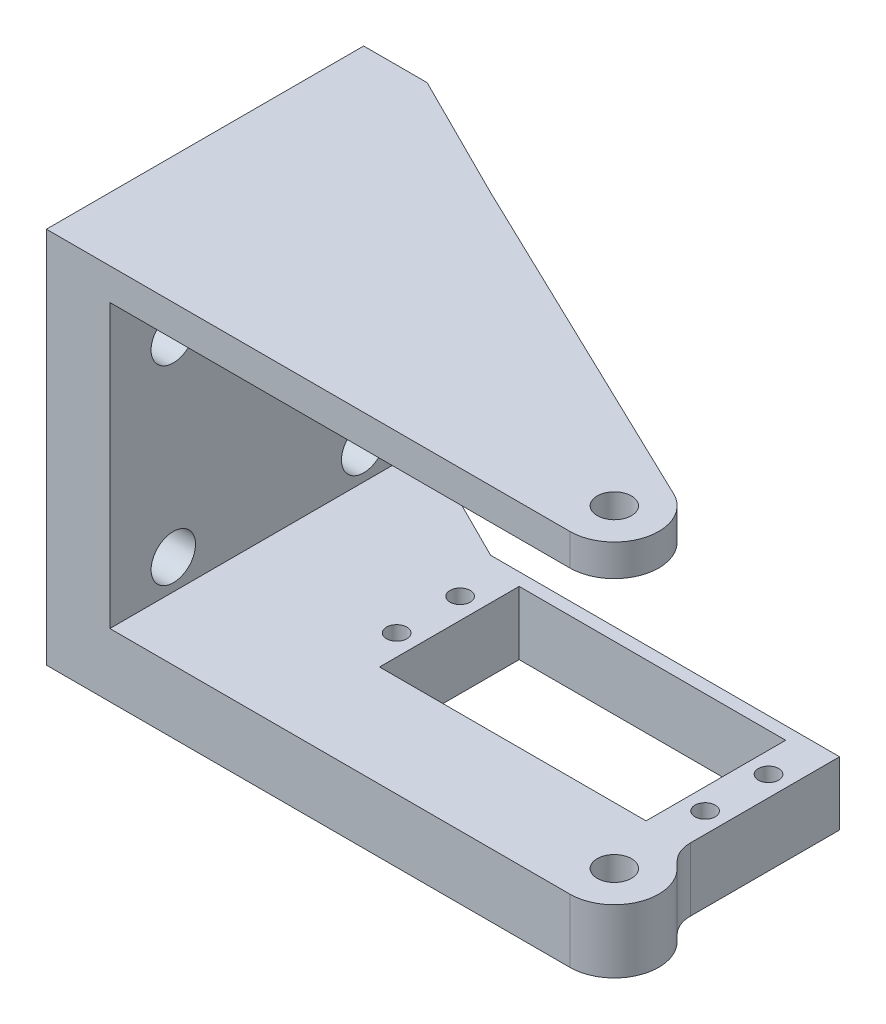
from build123d import *

# Parameters (mm, degrees)
SKETCH1_R           = 1.6
SKETCH1_R_2         = 5
SKETCH1_W           = 42
SKETCH1_H           = 22
BOSS_EXTRUDE1_DEPTH = 10
BOSS_EXTRUDE2_DEPTH = 10
BOSS_EXTRUDE4_START = 44.5
SKETCH2_R           = 5
BOSS_EXTRUDE4_DEPTH = 5
BOSS_EXTRUDE3_START = -10
SKETCH1_5_W         = 10
SKETCH1_5_H         = 50
BOSS_EXTRUDE3_DEPTH = 54.5
SKETCH3_R           = 3.5
CUT_EXTRUDE1_DEPTH  = 10
SKETCH4_R           = 5
SKETCH4_R_2         = 2.7
BOSS_EXTRUDE5_DEPTH = 10
BOSS_EXTRUDE6_START = 44.5
SKETCH4_2_R         = 5
SKETCH4_2_R_2       = 2.7
BOSS_EXTRUDE6_DEPTH = 5


with BuildPart() as part:
    # Sketch1 → Boss-Extrude1 (new body)
    with BuildSketch(Plane(origin=(0, 0, 0), x_dir=(1, 0, 0), z_dir=(0, 1, 0))):
        with BuildLine():
            Line((4.949747468, 4.949747468), (3.964466094, 5.935028843))
            ThreePointArc((3.964466094, 5.935028843), (2.880602337, 7.557145587), (2.5, 9.470562748))
            Line((2.5, 9.470562748), (2.5, 33))
            Line((2.5, 33), (-52.5, 33))
            Line((-52.5, 33), (-52.5, -7))
            Line((-52.5, -7), (0, -7))
            ThreePointArc((0, -7), (6.467156728, -2.678784027), (4.949747468, 4.949747468))
        make_face()
        with Locations((-49.3, 25)):
            Circle(SKETCH1_R, mode=Mode.SUBTRACT)
        with Locations((-49.3, 15)):
            Circle(SKETCH1_R, mode=Mode.SUBTRACT)
        with Locations((-0.7, 15)):
            Circle(SKETCH1_R, mode=Mode.SUBTRACT)
        with Locations((-0.7, 25)):
            Circle(SKETCH1_R, mode=Mode.SUBTRACT)
        Circle(SKETCH1_R_2, mode=Mode.SUBTRACT)
        with Locations((-25, 20)):
            Rectangle(SKETCH1_W, SKETCH1_H, mode=Mode.SUBTRACT)
    extrude(amount=-BOSS_EXTRUDE1_DEPTH)

    # Sketch1_4 → Boss-Extrude2 (add)
    with BuildSketch(Plane(origin=(0, 0, 0), x_dir=(1, 0, 0), z_dir=(0, 1, 0))):
        Polygon((-72.5, -7), (-52.5, -7), (-52.5, 33), (-72.5, 43), align=None)
    extrude(amount=-BOSS_EXTRUDE2_DEPTH)



with BuildPart() as body_2:
    # Sketch2 → Boss-Extrude4 (new body)
    with BuildSketch(Plane(origin=(0, 0, 0), x_dir=(1, 0, 0), z_dir=(0, 1, 0)).offset(BOSS_EXTRUDE4_START)):
        with BuildLine():
            Line((-72.5, 43), (-52.5, 33))
            Line((-52.5, 33), (3.032382393, 6.309093201))
            ThreePointArc((3.032382393, 6.309093201), (6.825088, -1.555047844), (0, -7))
            Line((0, -7), (-52.5, -7))
            Line((-52.5, -7), (-82.5, -7))
            Line((-82.5, -7), (-82.5, 43))
            Line((-82.5, 43), (-72.5, 43))
        make_face()
        Circle(SKETCH2_R, mode=Mode.SUBTRACT)
    extrude(amount=BOSS_EXTRUDE4_DEPTH)


with BuildPart() as part_1:
    add(part.part)

    add(body_2.part)  # Boss-Extrude3 merges body 2
    # Sketch1_5 → Boss-Extrude3 (add)
    with BuildSketch(Plane(origin=(0, 0, 0), x_dir=(1, 0, 0), z_dir=(0, 1, 0)).offset(BOSS_EXTRUDE3_START)):
        with Locations((-77.5, 18)):
            Rectangle(SKETCH1_5_W, SKETCH1_5_H)
    extrude(amount=BOSS_EXTRUDE3_DEPTH)

    # Sketch3 → Cut-Extrude1 (cut)
    with BuildSketch(Plane.ZY.offset(82.5)):
        with Locations((-3, 34.75)):
            Circle(SKETCH3_R)
        with Locations((-3, 4.75)):
            Circle(SKETCH3_R)
        with Locations((-33, 4.75)):
            Circle(SKETCH3_R)
        with Locations((-33, 34.75)):
            Circle(SKETCH3_R)
    extrude(amount=-CUT_EXTRUDE1_DEPTH, mode=Mode.SUBTRACT)

    # Sketch4 → Boss-Extrude5 (add)
    with BuildSketch(Plane(origin=(0, 0, 0), x_dir=(1, 0, 0), z_dir=(0, 1, 0))):
        Circle(SKETCH4_R)
        Circle(SKETCH4_R_2, mode=Mode.SUBTRACT)
    extrude(amount=-BOSS_EXTRUDE5_DEPTH)

    # Sketch4_2 → Boss-Extrude6 (add)
    with BuildSketch(Plane(origin=(0, 0, 0), x_dir=(1, 0, 0), z_dir=(0, 1, 0)).offset(BOSS_EXTRUDE6_START)):
        Circle(SKETCH4_2_R)
        Circle(SKETCH4_2_R_2, mode=Mode.SUBTRACT)
    extrude(amount=BOSS_EXTRUDE6_DEPTH)


solid = part_1.part
